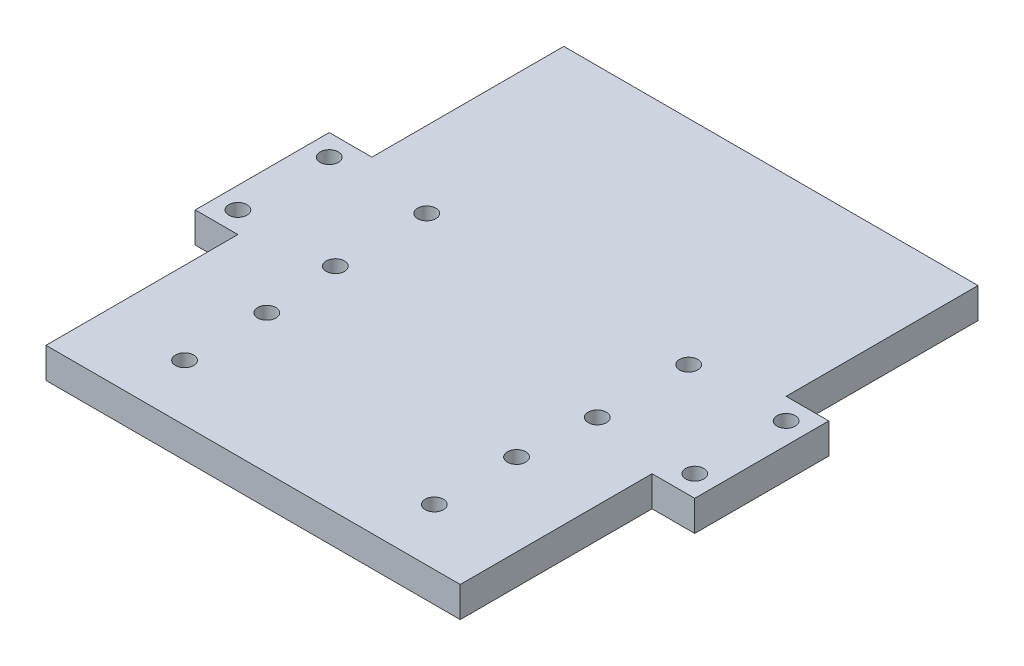
from build123d import *

# Parameters (mm, degrees)
SKETCH1_W           = 66
SKETCH1_H           = 85
BOSS_EXTRUDE1_DEPTH = 5
SKETCH5_W           = 22
SKETCH5_H           = 5
BOSS_EXTRUDE2_DEPTH = 7
SKETCH4_R           = 1.5
CUT_EXTRUDE2_DEPTH  = 10
SKETCH7_W           = 22
SKETCH7_H           = 5
BOSS_EXTRUDE3_DEPTH = 1
SKETCH8_W           = 22
SKETCH8_H           = 5
BOSS_EXTRUDE4_DEPTH = 1
SKETCH9_W           = 85
SKETCH9_H           = 5
BOSS_EXTRUDE5_DEPTH = 1
SKETCH10_W          = 85
SKETCH10_H          = 5
BOSS_EXTRUDE6_DEPTH = 1
SKETCH11_R          = 1.5
CUT_EXTRUDE3_DEPTH  = 10


with BuildPart() as part:
    # Sketch1 → Boss-Extrude1 (new body)
    with BuildSketch(Plane(origin=(0, 0, 0), x_dir=(1, 0, 0), z_dir=(0, 1, 0))):
        Rectangle(SKETCH1_W, SKETCH1_H)
    extrude(amount=BOSS_EXTRUDE1_DEPTH)

    # Sketch5 → Boss-Extrude2 (add)
    with BuildSketch(Plane.ZY.offset(33)):
        with Locations((0, 2.5)):
            Rectangle(SKETCH5_W, SKETCH5_H)
    boss_extrude2 = extrude(amount=BOSS_EXTRUDE2_DEPTH)

    # Mirror1: Boss-Extrude2 across plane
    add(boss_extrude2.mirror(Plane.ZY))

    # Sketch4 → Cut-Extrude2 (cut)
    with BuildSketch(Plane(origin=(0, 5, 0), x_dir=(1, 0, 0), z_dir=(0, 1, 0))):
        with Locations((-37.5, 7.5)):
            Circle(SKETCH4_R)
        with Locations((-21.5, 7.5)):
            Circle(SKETCH4_R)
        with Locations((-37.5, -7.5)):
            Circle(SKETCH4_R)
        with Locations((-21.5, -7.5)):
            Circle(SKETCH4_R)
        with Locations((21.5, -7.5)):
            Circle(SKETCH4_R)
        with Locations((37.5, -7.5)):
            Circle(SKETCH4_R)
        with Locations((21.5, 7.5)):
            Circle(SKETCH4_R)
        with Locations((37.5, 7.5)):
            Circle(SKETCH4_R)
    extrude(amount=-CUT_EXTRUDE2_DEPTH, mode=Mode.SUBTRACT)

    # Sketch7 → Boss-Extrude3 (add)
    with BuildSketch(Plane.ZY.offset(40)):
        with Locations((0, 2.5)):
            Rectangle(SKETCH7_W, SKETCH7_H)
    extrude(amount=BOSS_EXTRUDE3_DEPTH)

    # Sketch8 → Boss-Extrude4 (add)
    with BuildSketch(Plane(origin=(40, 0, 0), x_dir=(0, 0, -1), z_dir=(1, 0, 0))):
        with Locations((0, 2.5)):
            Rectangle(SKETCH8_W, SKETCH8_H)
    extrude(amount=BOSS_EXTRUDE4_DEPTH)

    # Sketch9 → Boss-Extrude5 (add)
    with BuildSketch(Plane.ZY.offset(33)):
        with Locations((0, 2.5)):
            Rectangle(SKETCH9_W, SKETCH9_H)
    extrude(amount=BOSS_EXTRUDE5_DEPTH)

    # Sketch10 → Boss-Extrude6 (add)
    with BuildSketch(Plane(origin=(33, 0, 0), x_dir=(0, 0, -1), z_dir=(1, 0, 0))):
        with Locations((0, 2.5)):
            Rectangle(SKETCH10_W, SKETCH10_H)
    extrude(amount=BOSS_EXTRUDE6_DEPTH)

    # Sketch11 → Cut-Extrude3 (cut)
    with BuildSketch(Plane(origin=(0, 5, 0), x_dir=(1, 0, 0), z_dir=(0, 1, 0))):
        with Locations((-20.5, -33.25)):
            Circle(SKETCH11_R)
        with Locations((-20.5, -19.75)):
            Circle(SKETCH11_R)
        with Locations((20.5, -33.25)):
            Circle(SKETCH11_R)
        with Locations((20.5, -19.75)):
            Circle(SKETCH11_R)
    extrude(amount=-CUT_EXTRUDE3_DEPTH, mode=Mode.SUBTRACT)


solid = part.part
